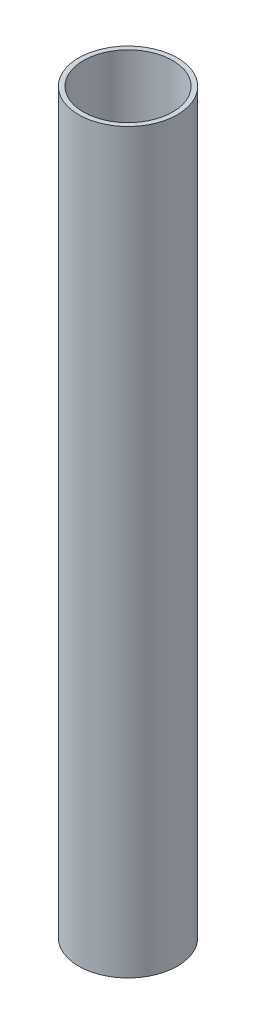
from build123d import *

# Parameters (mm, degrees)
SKETCH2_R           = 21
SKETCH2_R_2         = 19
EXTRUDE_THIN2_DEPTH = 314


with BuildPart() as part:
    # Sketch2 → Extrude-Thin2 (new body)
    with BuildSketch(Plane(origin=(0, 0, 0), x_dir=(1, 0, 0), z_dir=(0, 1, 0))):
        Circle(SKETCH2_R)
        Circle(SKETCH2_R_2, mode=Mode.SUBTRACT)
    extrude(amount=EXTRUDE_THIN2_DEPTH)


solid = part.part
